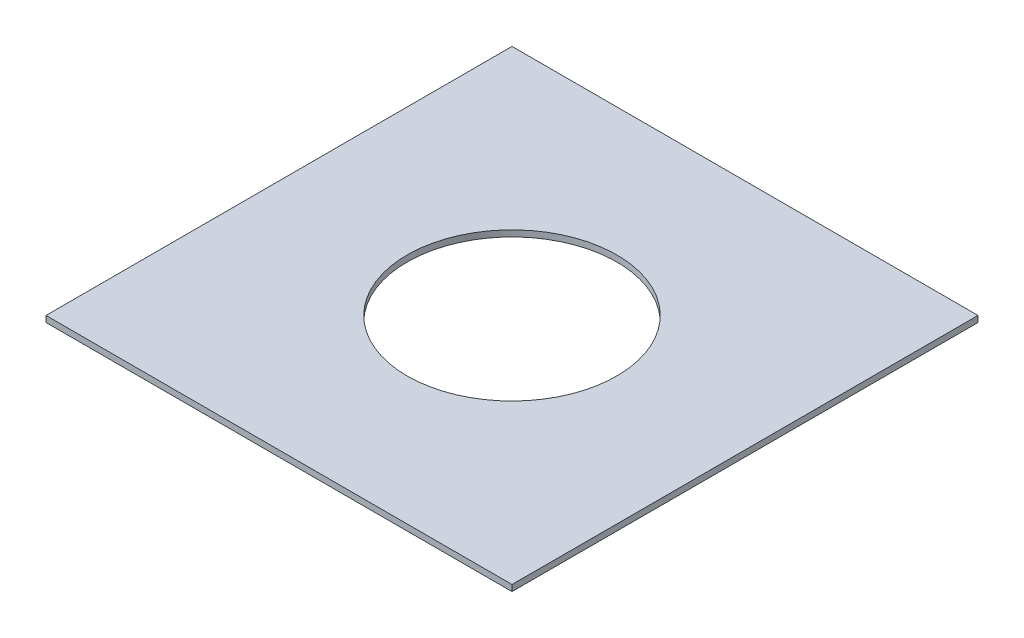
from build123d import *

# Parameters (mm, degrees)
SKETCH1_W           = 60
SKETCH1_H           = 60
SKETCH1_R           = 13.5
BOSS_EXTRUDE1_DEPTH = 0.79375


with BuildPart() as part:
    # Sketch1 → Boss-Extrude1 (new body)
    with BuildSketch(Plane(origin=(0, 0, 0), x_dir=(1, 0, 0), z_dir=(0, 1, 0))):
        with Locations((47.557337307, 0.540181073)):
            Rectangle(SKETCH1_W, SKETCH1_H)
        with Locations((47.557337307, 0.540181073)):
            Circle(SKETCH1_R, mode=Mode.SUBTRACT)
    extrude(amount=BOSS_EXTRUDE1_DEPTH)


solid = part.part
